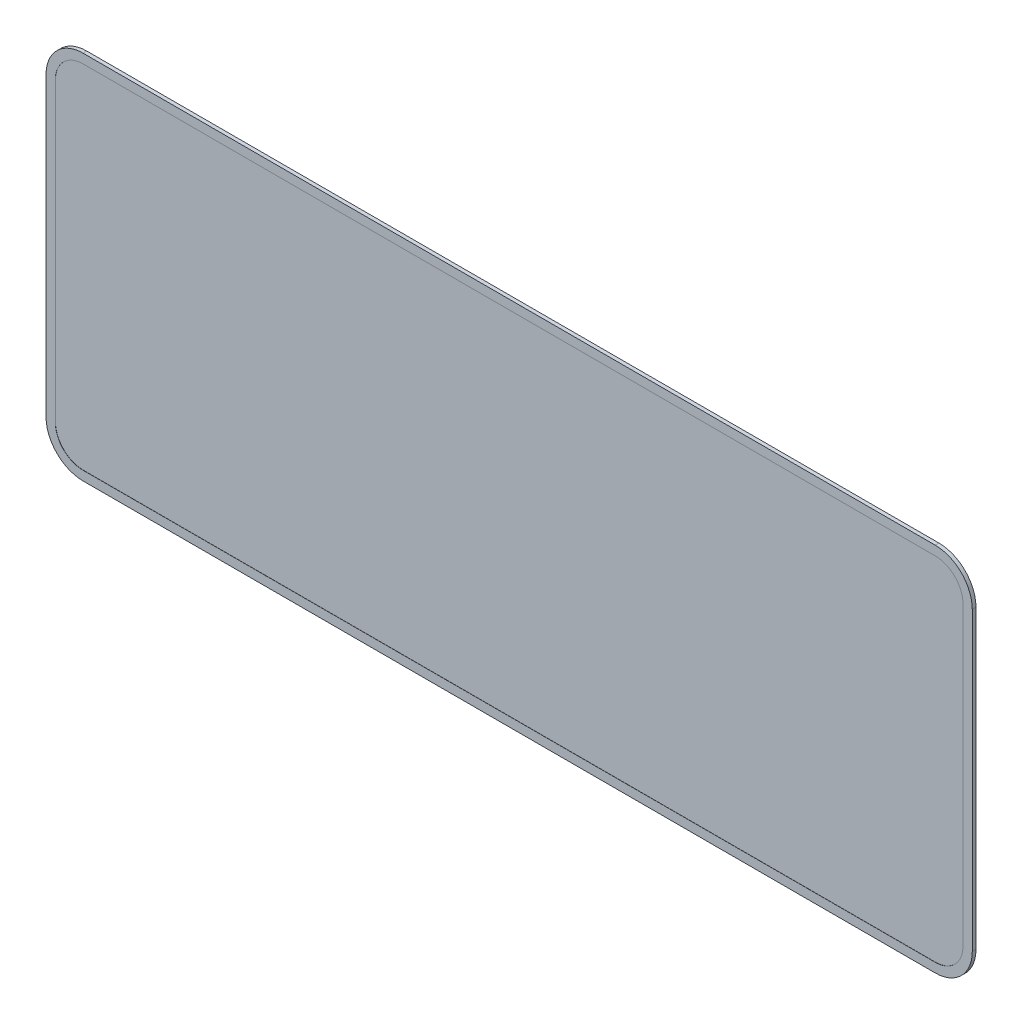
from build123d import *

# Parameters (mm, degrees)
BOSS_EXTRUDE1_DEPTH = 2
CUT_EXTRUDE1_DEPTH  = 0.1


with BuildPart() as part:
    # Sketch1 → Boss-Extrude1 (new body)
    with BuildSketch(Plane.XY):
        with BuildLine():
            Line((20, 0), (480, 0))
            ThreePointArc((480, 0), (494.142135624, 5.857864376), (500, 20))
            Line((500, 20), (500, 180))
            ThreePointArc((500, 180), (494.142135624, 194.142135624), (480, 200))
            Line((480, 200), (20, 200))
            ThreePointArc((20, 200), (5.857864376, 194.142135624), (0, 180))
            Line((0, 180), (0, 20))
            ThreePointArc((0, 20), (5.857864376, 5.857864376), (20, 0))
        make_face()
    extrude(amount=BOSS_EXTRUDE1_DEPTH)

    # Sketch3 → Cut-Extrude1 (cut)
    with BuildSketch(Plane.XY.offset(2)):
        with BuildLine():
            Line((495, 20), (495, 180))
            ThreePointArc((495, 180), (490.606601718, 190.606601718), (480, 195))
            Line((480, 195), (20, 195))
            ThreePointArc((20, 195), (9.393398282, 190.606601718), (5, 180))
            Line((5, 180), (5, 20))
            ThreePointArc((5, 20), (9.393398282, 9.393398282), (20, 5))
            Line((20, 5), (480, 5))
            ThreePointArc((480, 5), (490.606601718, 9.393398282), (495, 20))
        make_face()
    extrude(amount=-CUT_EXTRUDE1_DEPTH, mode=Mode.SUBTRACT)


solid = part.part
